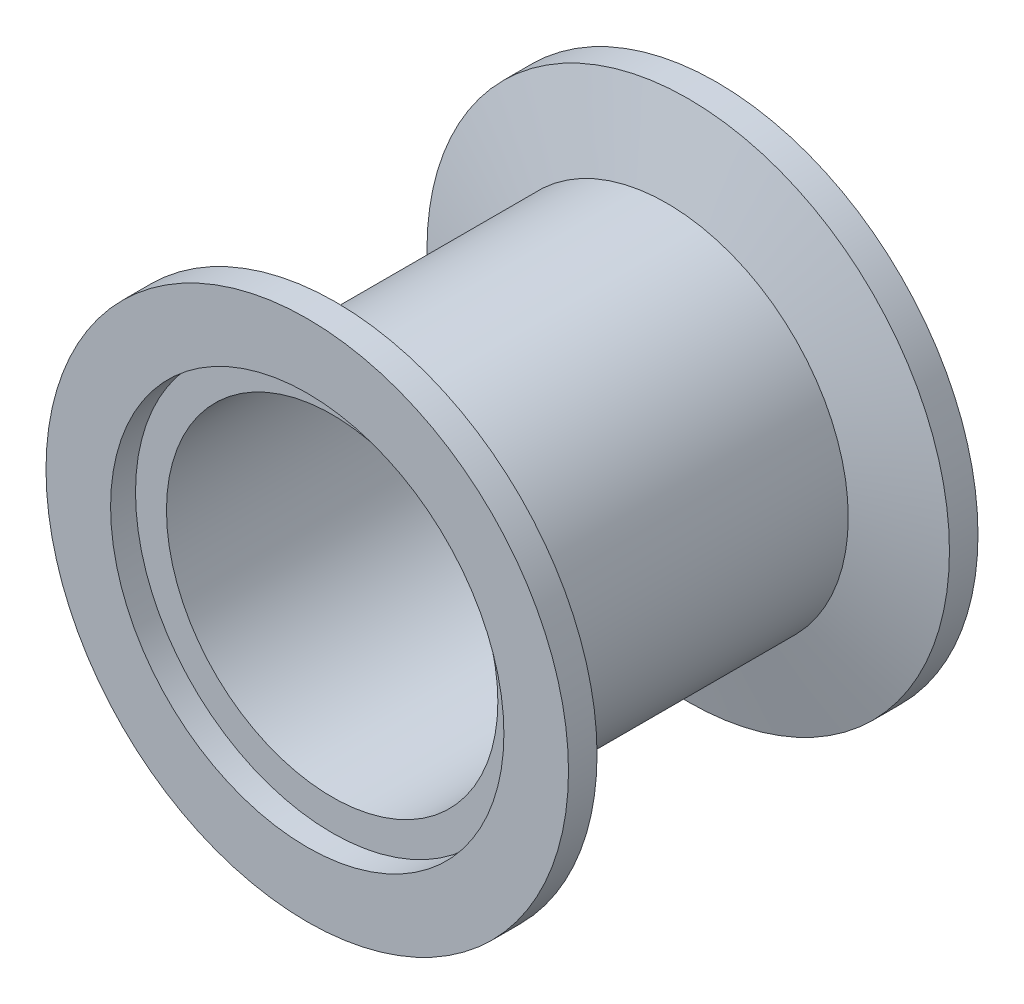
from build123d import *


with BuildPart() as part:
    # Sketch2 → Revolve1 (revolve)
    with BuildSketch(Plane(origin=(0, 0, 0), x_dir=(0, 0, -1), z_dir=(1, 0, 0))):
        Polygon((21.5, 20.6502), (21.5, 27.432), (18.5028, 27.432), (16.256849869, 19.05), (-16.256849869, 19.05), (-18.5028, 27.432), (-21.5, 27.432), (-21.5, 20.6502), (-18.8838, 20.6502), (-18.8838, 17.399), (18.8838, 17.399), (18.8838, 20.6502), align=None)
    revolve(axis=Axis((0, 0, 21.5), (0, 0, -1)))


solid = part.part
